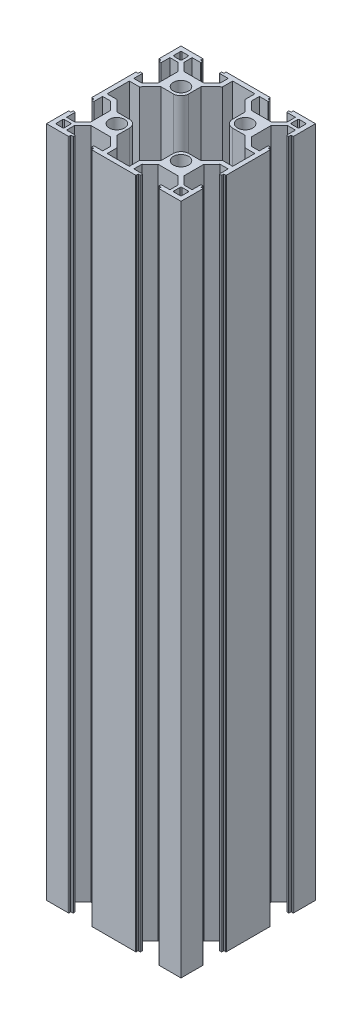
from build123d import *

# Parameters (mm, degrees)
SKETCH1_W                = 60
SKETCH1_H                = 60
BOSS_EXTRUDE1_DEPTH      = 300
CUT_EXTRUDE1_DEPTH       = 303.985148151
CIRPATTERN1_COUNT        = 4
CIRPATTERN1_COPY_1_DEPTH = 303.985148151
CIRPATTERN1_COPY_2_DEPTH = 303.985148151
CIRPATTERN1_COPY_3_DEPTH = 303.985148151
SKETCH4_R                = 3.4
CUT_EXTRUDE2_DEPTH       = 1000
FILLET1_R                = 0.2
FILLET2_R                = 0.2
FILLET3_R                = 0.2
FILLET4_R                = 0.2


with BuildPart() as part:
    # Sketch1 → Boss-Extrude1 (new body)
    with BuildSketch(Plane(origin=(0, 0, 0), x_dir=(1, 0, 0), z_dir=(0, 1, 0))):
        Rectangle(SKETCH1_W, SKETCH1_H)
        Polygon((-23.05, -28), (-6.95, -28), (-6.95, -24.4), (-10.615, -20.8), (-19.385, -20.8), (-23.05, -24.4), align=None, mode=Mode.SUBTRACT)
        Polygon((10.615, -20.8), (19.385, -20.8), (23.05, -24.4), (23.05, -28), (6.95, -28), (6.95, -24.4), align=None, mode=Mode.SUBTRACT)
        Polygon((19.385, 20.8), (23.05, 24.4), (23.05, 28), (6.95, 28), (6.95, 24.4), (10.615, 20.8), align=None, mode=Mode.SUBTRACT)
        Polygon((-23.05, 24.4), (-23.05, 28), (-6.95, 28), (-6.95, 24.4), (-10.615, 20.8), (-19.385, 20.8), align=None, mode=Mode.SUBTRACT)
        Polygon((-20.8, 19.385), (-24.4, 23.05), (-28, 23.05), (-28, 6.95), (-24.4, 6.95), (-20.8, 10.615), align=None, mode=Mode.SUBTRACT)
        Polygon((-24.4, -23.05), (-28, -23.05), (-28, -6.95), (-24.4, -6.95), (-20.8, -10.615), (-20.8, -19.385), align=None, mode=Mode.SUBTRACT)
        Polygon((20.8, -19.385), (24.4, -23.05), (28, -23.05), (28, -6.95), (24.4, -6.95), (20.8, -10.615), align=None, mode=Mode.SUBTRACT)
        Polygon((24.4, 23.05), (28, 23.05), (28, 6.95), (24.4, 6.95), (20.8, 10.615), (20.8, 19.385), align=None, mode=Mode.SUBTRACT)
    extrude(amount=BOSS_EXTRUDE1_DEPTH)

    # Sketch2 → Cut-Extrude1 (cut, through all)
    with BuildSketch(Plane(origin=(0, 300, 0), x_dir=(1, 0, 0), z_dir=(0, 1, 0))):
        Polygon((-19.1, -28), (-19.1, -29), (-20.1, -29), (-20.1, -30), (-9.9, -30), (-9.9, -29), (-10.9, -29), (-10.9, -28), align=None)
    cut_extrude1 = extrude(amount=-CUT_EXTRUDE1_DEPTH, mode=Mode.SUBTRACT)

    # Mirror1: Cut-Extrude1 across plane
    add(cut_extrude1.mirror(Plane(origin=(0, 0, 0), x_dir=(0, 0, 1), z_dir=(1, 0, 0))), mode=Mode.SUBTRACT)

    # CirPattern1: Cut-Extrude1 ×4 about axis
    cirpattern1_axis = Axis((0, 1050, 0), (0, -1, 0))
    for i in range(1, CIRPATTERN1_COUNT):
        add(cut_extrude1.rotate(cirpattern1_axis, i * 360 / CIRPATTERN1_COUNT), mode=Mode.SUBTRACT)

    # CirPattern1 copy 1 sketch → CirPattern1 copy 1 (cut, through all)
    with BuildSketch(Plane(origin=(0, 300, 0), x_dir=(0, 0, -1), z_dir=(0, 1, 0))):
        Polygon((-19.1, 28), (-19.1, 29), (-20.1, 29), (-20.1, 30), (-9.9, 30), (-9.9, 29), (-10.9, 29), (-10.9, 28), align=None)
    extrude(amount=-CIRPATTERN1_COPY_1_DEPTH, mode=Mode.SUBTRACT)

    # CirPattern1 copy 2 sketch → CirPattern1 copy 2 (cut, through all)
    with BuildSketch(Plane(origin=(0, 300, 0), x_dir=(1, 0, 0), z_dir=(0, 1, 0))):
        Polygon((-19.1, 28), (-19.1, 29), (-20.1, 29), (-20.1, 30), (-9.9, 30), (-9.9, 29), (-10.9, 29), (-10.9, 28), align=None)
    extrude(amount=-CIRPATTERN1_COPY_2_DEPTH, mode=Mode.SUBTRACT)

    # CirPattern1 copy 3 sketch → CirPattern1 copy 3 (cut, through all)
    with BuildSketch(Plane.ZX.offset(300)):
        Polygon((-19.1, 28), (-19.1, 29), (-20.1, 29), (-20.1, 30), (-9.9, 30), (-9.9, 29), (-10.9, 29), (-10.9, 28), align=None)
    extrude(amount=-CIRPATTERN1_COPY_3_DEPTH, mode=Mode.SUBTRACT)

    # Sketch4 → Cut-Extrude2 (cut)
    with BuildSketch(Plane(origin=(0, 300, 0), x_dir=(1, 0, 0), z_dir=(0, 1, 0))):
        with BuildLine():
            Line((-13.197035349, 9.797035349), (-18.8, 9.797035349))
            Line((-18.8, 9.797035349), (-23.561071557, 4.95))
            Line((-23.561071557, 4.95), (-28, 4.95))
            Line((-28, 4.95), (-28, -4.95))
            Line((-28, -4.95), (-23.561071557, -4.95))
            Line((-23.561071557, -4.95), (-18.8, -9.797035349))
            Line((-18.8, -9.797035349), (-13.197035349, -9.797035349))
            ThreePointArc((-13.197035349, -9.797035349), (-10.792872293, -10.792872293), (-9.797035349, -13.197035349))
            Line((-9.797035349, -13.197035349), (-9.797035349, -18.8))
            Line((-9.797035349, -18.8), (-4.95, -23.561071557))
            Line((-4.95, -23.561071557), (-4.95, -28))
            Line((-4.95, -28), (4.95, -28))
            Line((4.95, -28), (4.95, -23.561071557))
            Line((4.95, -23.561071557), (9.797035349, -18.8))
            Line((9.797035349, -18.8), (9.797035349, -13.197035349))
            ThreePointArc((9.797035349, -13.197035349), (10.792872293, -10.792872293), (13.197035349, -9.797035349))
            Line((13.197035349, -9.797035349), (18.8, -9.797035349))
            Line((18.8, -9.797035349), (23.561071557, -4.95))
            Line((23.561071557, -4.95), (28, -4.95))
            Line((28, -4.95), (28, 4.95))
            Line((28, 4.95), (23.561071557, 4.95))
            Line((23.561071557, 4.95), (18.8, 9.797035349))
            Line((18.8, 9.797035349), (13.197035349, 9.797035349))
            ThreePointArc((13.197035349, 9.797035349), (10.792872293, 10.792872293), (9.797035349, 13.197035349))
            Line((9.797035349, 13.197035349), (9.797035349, 18.8))
            Line((9.797035349, 18.8), (4.95, 23.561071557))
            Line((4.95, 23.561071557), (4.95, 28))
            Line((4.95, 28), (-4.95, 28))
            Line((-4.95, 28), (-4.95, 23.561071557))
            Line((-4.95, 23.561071557), (-9.797035349, 18.8))
            Line((-9.797035349, 18.8), (-9.797035349, 13.197035349))
            ThreePointArc((-9.797035349, 13.197035349), (-10.792872293, 10.792872293), (-13.197035349, 9.797035349))
        make_face()
        with BuildLine():
            ThreePointArc((-28, -27.5), (-27.853553391, -27.853553391), (-27.5, -28))
            Line((-27.5, -28), (-24.9, -28))
            ThreePointArc((-24.9, -28), (-24.546446609, -27.853553391), (-24.4, -27.5))
            Line((-24.4, -27.5), (-24.4, -24.9))
            ThreePointArc((-24.4, -24.9), (-24.546446609, -24.546446609), (-24.9, -24.4))
            Line((-24.9, -24.4), (-27.5, -24.4))
            ThreePointArc((-27.5, -24.4), (-27.853553391, -24.546446609), (-28, -24.9))
            Line((-28, -24.9), (-28, -27.5))
        make_face()
        with BuildLine():
            ThreePointArc((24.4, -27.5), (24.546446609, -27.853553391), (24.9, -28))
            Line((24.9, -28), (27.5, -28))
            ThreePointArc((27.5, -28), (27.853553391, -27.853553391), (28, -27.5))
            Line((28, -27.5), (28, -24.9))
            ThreePointArc((28, -24.9), (27.853553391, -24.546446609), (27.5, -24.4))
            Line((27.5, -24.4), (24.9, -24.4))
            ThreePointArc((24.9, -24.4), (24.546446609, -24.546446609), (24.4, -24.9))
            Line((24.4, -24.9), (24.4, -27.5))
        make_face()
        with BuildLine():
            ThreePointArc((-27.5, 28), (-27.853553391, 27.853553391), (-28, 27.5))
            Line((-28, 27.5), (-28, 24.9))
            ThreePointArc((-28, 24.9), (-27.853553391, 24.546446609), (-27.5, 24.4))
            Line((-27.5, 24.4), (-24.9, 24.4))
            ThreePointArc((-24.9, 24.4), (-24.546446609, 24.546446609), (-24.4, 24.9))
            Line((-24.4, 24.9), (-24.4, 27.5))
            ThreePointArc((-24.4, 27.5), (-24.546446609, 27.853553391), (-24.9, 28))
            Line((-24.9, 28), (-27.5, 28))
        make_face()
        with BuildLine():
            ThreePointArc((28, 27.5), (27.853553391, 27.853553391), (27.5, 28))
            Line((27.5, 28), (24.9, 28))
            ThreePointArc((24.9, 28), (24.546446609, 27.853553391), (24.4, 27.5))
            Line((24.4, 27.5), (24.4, 24.9))
            ThreePointArc((24.4, 24.9), (24.546446609, 24.546446609), (24.9, 24.4))
            Line((24.9, 24.4), (27.5, 24.4))
            ThreePointArc((27.5, 24.4), (27.853553391, 24.546446609), (28, 24.9))
            Line((28, 24.9), (28, 27.5))
        make_face()
        with Locations((14.298517674, 14.298517674)):
            Circle(SKETCH4_R)
        with Locations((14.298517674, -14.298517674)):
            Circle(SKETCH4_R)
        with Locations((-14.298517674, -14.298517674)):
            Circle(SKETCH4_R)
        with Locations((-14.298517674, 14.298517674)):
            Circle(SKETCH4_R)
    extrude(amount=-CUT_EXTRUDE2_DEPTH, mode=Mode.SUBTRACT)

    # Fillet1
    fillet1_edges = [part.edges().sort_by_distance(p)[0] for p in [
        (28, 150, -19.1),
        (30, 150, -20.1),
        (29, 150, -20.1),
        (29, 150, -19.1),
        (28, 150, 10.9),
        (29, 150, 9.9),
        (28, 150, 19.1),
        (29, 150, 20.1),
        (30, 150, 20.1),
        (29, 150, 19.1),
        (29, 150, 10.9),
        (30, 150, 9.9),
        (30, 150, -9.9),
        (29, 150, -9.9),
        (29, 150, -10.9),
        (28, 150, -10.9),
    ]]
    fillet(fillet1_edges, radius=FILLET1_R)

    # Fillet2
    fillet2_edges = [part.edges().sort_by_distance(p)[0] for p in [
        (-20.1, 0, -29.5),
        (-20.1, 300, -29.5),
        (-20.1, 150, -29),
        (-19.6, 0, -29),
        (-19.1, 150, -29),
        (-19.6, 300, -29),
        (-9.9, 150, -30),
        (-10.9, 150, -28),
        (-10.9, 150, -29),
        (-9.9, 150, -29),
        (19.1, 150, -28),
        (19.1, 150, -29),
        (20.1, 150, -29),
        (20.1, 150, -30),
        (10.9, 150, -28),
        (10.9, 150, -29),
        (9.9, 150, -29),
        (9.9, 150, -30),
        (-19.1, 150, -28),
        (-20.1, 150, -30),
    ]]
    fillet(fillet2_edges, radius=FILLET2_R)

    # Fillet3
    fillet3_edges = [part.edges().sort_by_distance(p)[0] for p in [
        (-29, 150, 9.9),
        (-29, 150, -20.1),
        (-30, 150, -20.1),
        (-29, 150, -19.1),
        (-28, 150, -10.9),
        (-29, 150, -10.9),
        (-29, 150, -9.9),
        (-30, 150, -9.9),
        (-29, 150, 10.9),
        (-30, 150, 9.9),
        (-28, 150, 19.1),
        (-29, 150, 19.1),
        (-29, 150, 20.1),
        (-30, 150, 20.1),
    ]]
    fillet(fillet3_edges, radius=FILLET3_R)

    # Fillet4
    fillet4_edges = [part.edges().sort_by_distance(p)[0] for p in [
        (-19.1, 150, 28),
        (10.9, 150, 28),
        (19.1, 150, 28),
        (20.1, 150, 29),
        (-10.9, 150, 28),
        (-9.9, 150, 29),
        (9.9, 150, 29),
        (-20.1, 150, 29),
        (19.1, 150, 29),
        (20.1, 150, 30),
        (10.9, 150, 29),
        (9.9, 150, 30),
        (-9.9, 150, 30),
        (-10.9, 150, 29),
        (-19.1, 150, 29),
        (-20.1, 150, 30),
    ]]
    fillet(fillet4_edges, radius=FILLET4_R)


solid = part.part
